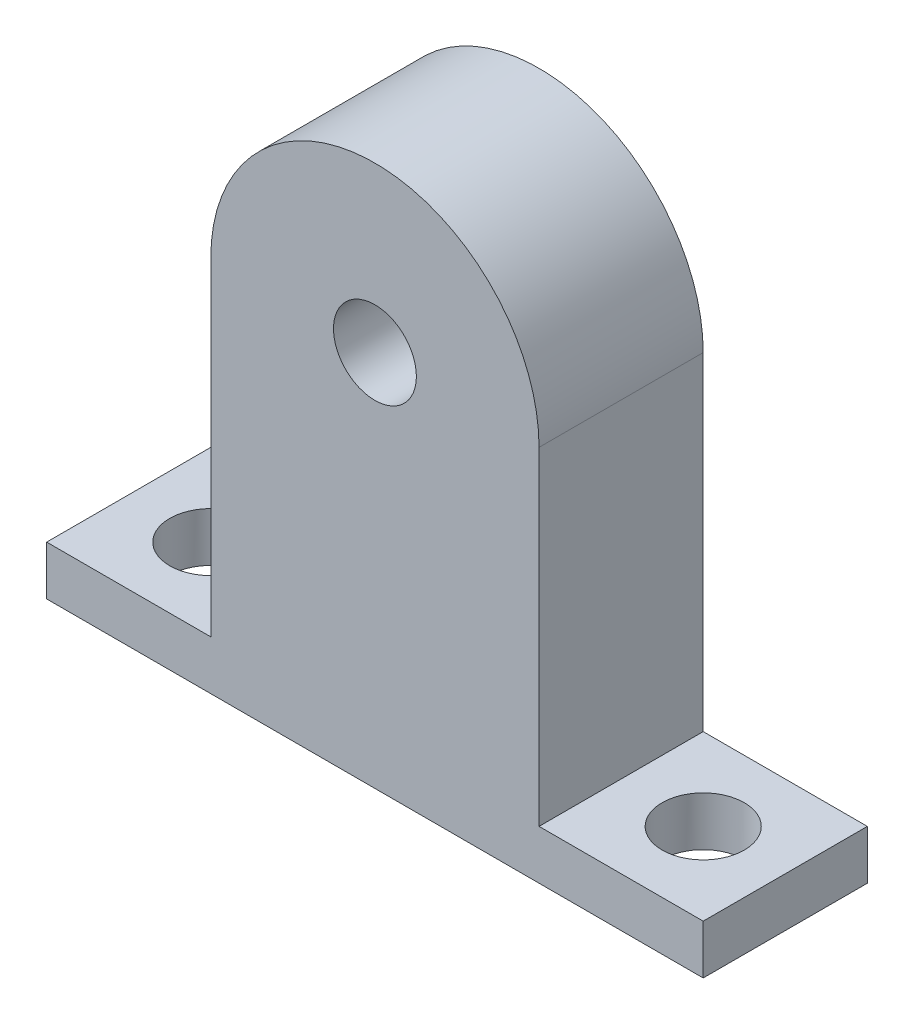
from build123d import *

# Parameters (mm, degrees)
SKETCH2_W           = 101.6
SKETCH2_H           = 25.4
BOSS_EXTRUDE1_DEPTH = 7.62
BOSS_EXTRUDE2_DEPTH = 12.7
SKETCH4_R           = 6.35635
CUT_EXTRUDE1_DEPTH  = 7.62
CUT_EXTRUDE2_REACH  = 27.4
SKETCH5_R           = 6.4135


with BuildPart() as part:
    # Sketch2 → Boss-Extrude1 (new body)
    with BuildSketch(Plane(origin=(0, 0, 0), x_dir=(1, 0, 0), z_dir=(0, 1, 0))):
        Rectangle(SKETCH2_W, SKETCH2_H)
    extrude(amount=BOSS_EXTRUDE1_DEPTH)

    # Sketch3 → Boss-Extrude2 (add, symmetric)
    with BuildSketch(Plane.XY):
        with BuildLine():
            ThreePointArc((25.4, 58.42), (0, 83.82), (-25.4, 58.42))
            Line((-25.4, 58.42), (25.4, 58.42))
        make_face()
        with BuildLine():
            Line((25.4, 58.42), (-25.4, 58.42))
            ThreePointArc((-25.4, 58.42), (0, 33.02), (25.4, 58.42))
        make_face()
        with BuildLine():
            Line((-25.4, 58.42), (-25.4, 7.62))
            Line((-25.4, 7.62), (25.4, 7.62))
            Line((25.4, 7.62), (25.4, 58.42))
            ThreePointArc((25.4, 58.42), (0, 33.02), (-25.4, 58.42))
        make_face()
    extrude(amount=BOSS_EXTRUDE2_DEPTH, both=True)

    # Sketch4 → Cut-Extrude1 (cut)
    with BuildSketch(Plane(origin=(0, 7.62, 0), x_dir=(1, 0, 0), z_dir=(0, 1, 0))):
        with Locations((38.1, 0)):
            Circle(SKETCH4_R)
    cut_extrude1 = extrude(amount=-CUT_EXTRUDE1_DEPTH, mode=Mode.SUBTRACT)

    # Mirror1: Cut-Extrude1 across plane
    add(cut_extrude1.mirror(Plane(origin=(0, 0, 0), x_dir=(0, 0, 1), z_dir=(1, 0, 0))), mode=Mode.SUBTRACT)

    # Sketch5 → Cut-Extrude2 (cut, up to next)
    with BuildSketch(Plane.XY.offset(12.7), mode=Mode.PRIVATE) as cut_extrude2_sk1:
        with Locations((0, 58.42)):
            Circle(SKETCH5_R)
    cut_extrude2_tool1 = extrude(cut_extrude2_sk1.sketch, amount=-CUT_EXTRUDE2_REACH, mode=Mode.PRIVATE) & part.part
    add(cut_extrude2_tool1.solids().sort_by_distance((0, 58.42, 12.7))[0], mode=Mode.SUBTRACT)


solid = part.part
